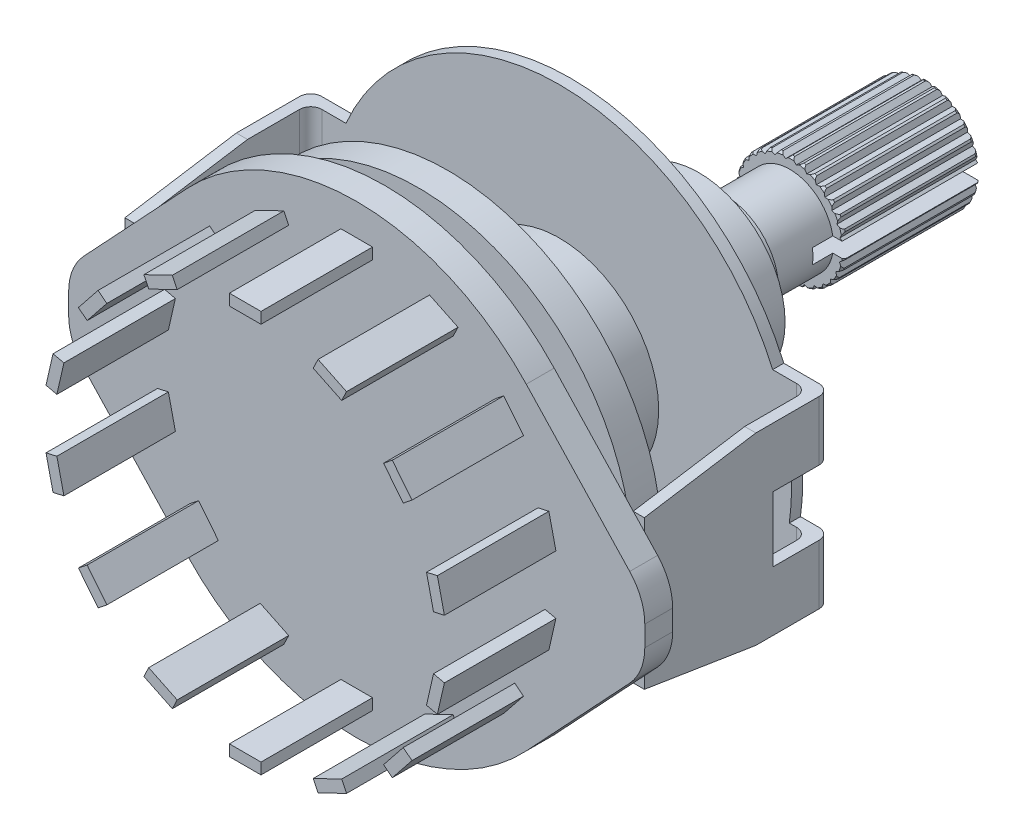
from build123d import *

# Parameters (mm, degrees)
CROQUIS1_R               = 2.95
SALIENTE_EXTRUIR1_DEPTH  = 7.3
CROQUIS2_R               = 2.35
SALIENTE_EXTRUIR2_DEPTH  = 3.5
CROQUIS3_R               = 2.9
SALIENTE_EXTRUIR3_DEPTH  = 1.4
CROQUIS4_R               = 4.65
SALIENTE_EXTRUIR4_DEPTH  = 6
CROQUIS5_R               = 5.35
SALIENTE_EXTRUIR5_DEPTH  = 0.9
SALIENTE_EXTRUIR6_DEPTH  = 0.6
SALIENTE_EXTRUIR7_DEPTH  = 0.6
SALIENTE_EXTRUIR8_DEPTH  = 0.6
REDONDEO1_R              = 0.6
SALIENTE_EXTRUIR9_START  = -0.6
CROQUIS13_W              = 3
CROQUIS13_H              = 0.2
SALIENTE_EXTRUIR9_DEPTH  = 2
CROQUIS14_W              = 0.6
CROQUIS14_H              = 4
SALIENTE_EXTRUIR10_DEPTH = 1.5
SALIENTE_EXTRUIR11_START = 9.4
SALIENTE_EXTRUIR11_DEPTH = 1.5
REDONDEO2_R              = 3
CORTAR_EXTRUIR1_DEPTH    = 7.3
CROQUIS17_W              = 6.48560832
CROQUIS17_H              = 0.8
CORTAR_EXTRUIR2_DEPTH    = 8.4
CROQUIS19_W              = 1.7
CROQUIS19_H              = 0.6
SALIENTE_EXTRUIR12_DEPTH = 6
CROQUIS20_R              = 5.35
SALIENTE_EXTRUIR13_DEPTH = 6
CROQUIS21_R              = 11.5
SALIENTE_EXTRUIR14_DEPTH = 1.6


with BuildPart() as part:
    # Croquis1 → Saliente-Extruir1 (new body)
    with BuildSketch(Plane.XY):
        Circle(CROQUIS1_R)
    extrude(amount=SALIENTE_EXTRUIR1_DEPTH)

    # Croquis2 → Saliente-Extruir2 (add)
    with BuildSketch(Plane.XY.offset(7.3)):
        Circle(CROQUIS2_R)
    extrude(amount=SALIENTE_EXTRUIR2_DEPTH)

    # Croquis3 → Saliente-Extruir3 (add)
    with BuildSketch(Plane.XY.offset(10.8)):
        Circle(CROQUIS3_R)
    extrude(amount=SALIENTE_EXTRUIR3_DEPTH)

    # Croquis4 → Saliente-Extruir4 (add)
    with BuildSketch(Plane.XY.offset(12.2)):
        Circle(CROQUIS4_R)
    extrude(amount=SALIENTE_EXTRUIR4_DEPTH)

    # Croquis5 → Saliente-Extruir5 (add)
    with BuildSketch(Plane.XY.offset(18.2)):
        Circle(CROQUIS5_R)
    extrude(amount=SALIENTE_EXTRUIR5_DEPTH)

    # Croquis6 → Saliente-Extruir6 (add)
    with BuildSketch(Plane.XY.offset(19.1)):
        with BuildLine():
            Line((-5.5, -11.22497216), (5.5, -11.22497216))
            ThreePointArc((5.5, -11.22497216), (0, 12.5), (-5.5, -11.22497216))
        make_face()
    extrude(amount=SALIENTE_EXTRUIR6_DEPTH)

    # Croquis11 → Saliente-Extruir7 (add)
    with BuildSketch(Plane.XY.offset(19.7)):
        with BuildLine():
            Line((-12.376893794, 1.75), (-13.376893794, 1.75))
            Line((-13.376893794, 1.75), (-13.376893794, 4.95))
            Line((-13.376893794, 4.95), (-11.478131381, 4.95))
            ThreePointArc((-11.478131381, 4.95), (-12.034349028, 3.38000643), (-12.376893794, 1.75))
        make_face()
        with BuildLine():
            Line((-11.478131381, -4.95), (-13.376893794, -4.95))
            Line((-13.376893794, -4.95), (-13.376893794, -1.75))
            Line((-13.376893794, -1.75), (-12.376893794, -1.75))
            ThreePointArc((-12.376893794, -1.75), (-12.034349028, -3.38000643), (-11.478131381, -4.95))
        make_face()
    saliente_extruir7 = extrude(amount=-SALIENTE_EXTRUIR7_DEPTH)

    # Croquis12 → Saliente-Extruir8 (add)
    with BuildSketch(Plane.ZY.offset(13.376893794)):
        Polygon((19.1, 4.95), (23.1, 4.95), (29.1, 4), (29.1, -4), (23.1, -4.95), (19.1, -4.95), (19.1, -1.75), (22.18648426, -1.75), (22.18648426, 1.75), (19.1, 1.75), align=None)
    saliente_extruir8 = extrude(amount=SALIENTE_EXTRUIR8_DEPTH)

    # Simetría1: Saliente-Extruir7, Saliente-Extruir8 across plane
    add(saliente_extruir7.mirror(Plane(origin=(0, 0, 0), x_dir=(0, 0, 1), z_dir=(1, 0, 0))))
    add(saliente_extruir8.mirror(Plane(origin=(0, 0, 0), x_dir=(0, 0, 1), z_dir=(1, 0, 0))))

    # Redondeo1
    redondeo1_edges = [part.edges().sort_by_distance(p)[0] for p in [
        (13.976893794, 3.35, 19.1),
        (13.976893794, -3.35, 19.1),
        (-13.376893794, 3.35, 19.7),
        (-13.376893794, -3.35, 19.7),
        (-13.976893794, 3.35, 19.1),
        (-13.976893794, -3.35, 19.1),
        (13.376893794, 3.35, 19.7),
        (13.376893794, -3.35, 19.7),
    ]]
    fillet(redondeo1_edges, radius=REDONDEO1_R)

    # Croquis14 → Saliente-Extruir10 (add)
    with BuildSketch(Plane.XY.offset(29.1)):
        with Locations((13.676893794, 0)):
            Rectangle(CROQUIS14_W, CROQUIS14_H)
    saliente_extruir10 = extrude(amount=SALIENTE_EXTRUIR10_DEPTH)

    # Simetría2: Saliente-Extruir10 across plane
    add(saliente_extruir10.mirror(Plane(origin=(0, 0, 0), x_dir=(0, 0, 1), z_dir=(1, 0, 0))))

    # Croquis15 → Saliente-Extruir11 (add)
    with BuildSketch(Plane.XY.offset(19.7).offset(SALIENTE_EXTRUIR11_START)):
        with BuildLine():
            Line((15.5, 0), (15.5, 1.737141545))
            Line((15.5, 1.737141545), (9.122943906, 8.545284928))
            ThreePointArc((9.122943906, 8.545284928), (0, 12.5), (-9.122943906, 8.545284928))
            Line((-9.122943906, 8.545284928), (-15.5, 1.737141545))
            Line((-15.5, 1.737141545), (-15.5, 0))
            Line((-15.5, 0), (-15.5, -1.737141545))
            Line((-15.5, -1.737141545), (-9.122943906, -8.545284928))
            ThreePointArc((-9.122943906, -8.545284928), (0, -12.5), (9.122943906, -8.545284928))
            Line((9.122943906, -8.545284928), (15.5, -1.737141545))
            Line((15.5, -1.737141545), (15.5, 0))
        make_face()
    extrude(amount=SALIENTE_EXTRUIR11_DEPTH)

    # Redondeo2
    redondeo2_edges = [part.edges().sort_by_distance(p)[0] for p in [
        (-15.5, -1.737141545, 29.85),
        (15.5, -1.737141545, 29.85),
        (15.5, 1.737141545, 29.85),
        (-15.5, 1.737141545, 29.85),
    ]]
    fillet(redondeo2_edges, radius=REDONDEO2_R)

    # Croquis16 → Cortar-Extruir1 (cut)
    with BuildSketch(Plane(origin=(0, 0, 0), x_dir=(-1, 0, 0), z_dir=(0, 0, -1))):
        with BuildLine():
            Line((-0.015316198, 2.949960239), (0.217779302, 2.737792626))
            Line((0.217779302, 2.737792626), (0.483717289, 2.910071749))
            ThreePointArc((0.483717289, 2.910071749), (0.235048226, 2.940621079), (-0.015316198, 2.949960239))
        make_face()
        with BuildLine():
            Line((0.782239396, 2.632686425), (1.078184844, 2.74590922))
            ThreePointArc((1.078184844, 2.74590922), (0.841301359, 2.827492179), (0.598349719, 2.888680947))
            Line((0.598349719, 2.888680947), (0.782239396, 2.632686425))
        make_face()
        with BuildLine():
            Line((1.312511874, 2.412519195), (1.625530547, 2.461737281))
            ThreePointArc((1.625530547, 2.461737281), (1.410785586, 2.590788303), (1.185864882, 2.701152436))
            Line((1.185864882, 2.701152436), (1.312511874, 2.412519195))
        make_face()
        with BuildLine():
            Line((1.785421286, 2.086913299), (2.101832765, 2.069975611))
            ThreePointArc((2.101832765, 2.069975611), (1.918611712, 2.240854546), (1.721552059, 2.395570601))
            Line((1.721552059, 2.395570601), (1.785421286, 2.086913299))
        make_face()
        with BuildLine():
            Line((2.18029922, 1.670099278), (2.486274805, 1.587746073))
            ThreePointArc((2.486274805, 1.587746073), (2.342585301, 1.792984693), (2.181999151, 1.985290837))
            Line((2.181999151, 1.985290837), (2.18029922, 1.670099278))
        make_face()
        with BuildLine():
            Line((2.479887615, 1.180293905), (2.762054706, 1.036124414))
            ThreePointArc((2.762054706, 1.036124414), (2.664176671, 1.266752805), (2.547082409, 1.488244336))
            Line((2.547082409, 1.488244336), (2.479887615, 1.180293905))
        make_face()
        with BuildLine():
            Line((2.671093022, 0.638904024), (2.917119563, 0.439219145))
            ThreePointArc((2.917119563, 0.439219145), (2.869330736, 0.68515774), (2.800845943, 0.926154416))
            Line((2.800845943, 0.926154416), (2.671093022, 0.638904024))
        make_face()
        with BuildLine():
            Line((2.745558847, 0.069590972), (2.944692296, -0.176882107))
            ThreePointArc((2.944692296, -0.176882107), (2.949081279, 0.073617995), (2.93219907, 0.323587104))
            Line((2.93219907, 0.323587104), (2.745558847, 0.069590972))
        make_face()
        with BuildLine():
            Line((2.700030576, -0.50276354), (2.843567847, -0.785252763))
            ThreePointArc((2.843567847, -0.785252763), (2.899942819, -0.54113921), (2.935401027, -0.293122517))
            Line((2.935401027, -0.293122517), (2.700030576, -0.50276354))
        make_face()
        with BuildLine():
            Line((2.536498012, -1.053144873), (2.618165837, -1.359304105))
            ThreePointArc((2.618165837, -1.359304105), (2.724062943, -1.132246035), (2.810311874, -0.897021277))
            Line((2.810311874, -0.897021277), (2.536498012, -1.053144873))
        make_face()
        with BuildLine():
            Line((2.262108313, -1.557498721), (2.278337417, -1.873947335))
            ThreePointArc((2.278337417, -1.873947335), (2.429128444, -1.673868274), (2.562398606, -1.461715904))
            Line((2.562398606, -1.461715904), (2.262108313, -1.557498721))
        make_face()
        with BuildLine():
            Line((1.888853627, -1.993782401), (1.838934719, -2.306690074))
            ThreePointArc((1.838934719, -2.306690074), (2.028029377, -2.142334439), (2.202496224, -1.962526531))
            Line((2.202496224, -1.962526531), (1.888853627, -1.993782401))
        make_face()
        with BuildLine():
            Line((1.433046973, -2.342928223), (1.31916175, -2.638619389))
            ThreePointArc((1.31916175, -2.638619389), (1.538295694, -2.517170308), (1.746334188, -2.377565331))
            Line((1.746334188, -2.377565331), (1.433046973, -2.342928223))
        make_face()
        with BuildLine():
            Line((0.91460929, -2.58967684), (0.741735082, -2.855228374))
            ThreePointArc((0.741735082, -2.855228374), (0.981331107, -2.781993756), (1.213848968, -2.688693118))
            Line((1.213848968, -2.688693118), (0.91460929, -2.58967684))
        make_face()
        with BuildLine():
            Line((0.356198792, -2.723244151), (0.131891032, -2.947050179))
            ThreePointArc((0.131891032, -2.947050179), (0.381477642, -2.925230727), (0.628312723, -2.882312114))
            Line((0.628312723, -2.882312114), (0.356198792, -2.723244151))
        make_face()
        with BuildLine():
            Line((-0.217779302, -2.737792626), (-0.483717289, -2.910071749))
            ThreePointArc((-0.483717289, -2.910071749), (-0.235048226, -2.940621079), (0.015316198, -2.949960239))
            Line((0.015316198, -2.949960239), (-0.217779302, -2.737792626))
        make_face()
        with BuildLine():
            Line((-0.782239396, -2.632686425), (-1.078184844, -2.74590922))
            ThreePointArc((-1.078184844, -2.74590922), (-0.841301359, -2.827492179), (-0.598349719, -2.888680947))
            Line((-0.598349719, -2.888680947), (-0.782239396, -2.632686425))
        make_face()
        with BuildLine():
            Line((-1.312511874, -2.412519195), (-1.625530547, -2.461737281))
            ThreePointArc((-1.625530547, -2.461737281), (-1.410785586, -2.590788303), (-1.185864882, -2.701152436))
            Line((-1.185864882, -2.701152436), (-1.312511874, -2.412519195))
        make_face()
        with BuildLine():
            Line((-1.785421286, -2.086913299), (-2.101832765, -2.069975611))
            ThreePointArc((-2.101832765, -2.069975611), (-1.918611712, -2.240854546), (-1.721552059, -2.395570601))
            Line((-1.721552059, -2.395570601), (-1.785421286, -2.086913299))
        make_face()
        with BuildLine():
            Line((-2.18029922, -1.670099278), (-2.486274805, -1.587746073))
            ThreePointArc((-2.486274805, -1.587746073), (-2.342585301, -1.792984693), (-2.181999151, -1.985290837))
            Line((-2.181999151, -1.985290837), (-2.18029922, -1.670099278))
        make_face()
        with BuildLine():
            Line((-2.479887615, -1.180293905), (-2.762054706, -1.036124414))
            ThreePointArc((-2.762054706, -1.036124414), (-2.664176671, -1.266752805), (-2.547082409, -1.488244336))
            Line((-2.547082409, -1.488244336), (-2.479887615, -1.180293905))
        make_face()
        with BuildLine():
            Line((-2.671093022, -0.638904024), (-2.917119563, -0.439219145))
            ThreePointArc((-2.917119563, -0.439219145), (-2.869330736, -0.68515774), (-2.800845943, -0.926154416))
            Line((-2.800845943, -0.926154416), (-2.671093022, -0.638904024))
        make_face()
        with BuildLine():
            Line((-2.745558847, -0.069590972), (-2.944692296, 0.176882107))
            ThreePointArc((-2.944692296, 0.176882107), (-2.949081279, -0.073617995), (-2.93219907, -0.323587104))
            Line((-2.93219907, -0.323587104), (-2.745558847, -0.069590972))
        make_face()
        with BuildLine():
            Line((-2.700030576, 0.50276354), (-2.843567847, 0.785252763))
            ThreePointArc((-2.843567847, 0.785252763), (-2.899942819, 0.54113921), (-2.935401027, 0.293122517))
            Line((-2.935401027, 0.293122517), (-2.700030576, 0.50276354))
        make_face()
        with BuildLine():
            Line((-2.536498012, 1.053144873), (-2.618165837, 1.359304105))
            ThreePointArc((-2.618165837, 1.359304105), (-2.724062943, 1.132246035), (-2.810311874, 0.897021277))
            Line((-2.810311874, 0.897021277), (-2.536498012, 1.053144873))
        make_face()
        with BuildLine():
            Line((-2.262108313, 1.557498721), (-2.278337417, 1.873947335))
            ThreePointArc((-2.278337417, 1.873947335), (-2.429128444, 1.673868274), (-2.562398606, 1.461715904))
            Line((-2.562398606, 1.461715904), (-2.262108313, 1.557498721))
        make_face()
        with BuildLine():
            Line((-1.888853627, 1.993782401), (-1.838934719, 2.306690074))
            ThreePointArc((-1.838934719, 2.306690074), (-2.028029377, 2.142334439), (-2.202496224, 1.962526531))
            Line((-2.202496224, 1.962526531), (-1.888853627, 1.993782401))
        make_face()
        with BuildLine():
            Line((-1.433046973, 2.342928223), (-1.31916175, 2.638619389))
            ThreePointArc((-1.31916175, 2.638619389), (-1.538295694, 2.517170308), (-1.746334188, 2.377565331))
            Line((-1.746334188, 2.377565331), (-1.433046973, 2.342928223))
        make_face()
        with BuildLine():
            Line((-0.91460929, 2.58967684), (-0.741735082, 2.855228374))
            ThreePointArc((-0.741735082, 2.855228374), (-0.981331107, 2.781993756), (-1.213848968, 2.688693118))
            Line((-1.213848968, 2.688693118), (-0.91460929, 2.58967684))
        make_face()
        with BuildLine():
            Line((-0.356198792, 2.723244151), (-0.131891032, 2.947050179))
            ThreePointArc((-0.131891032, 2.947050179), (-0.381477642, 2.925230727), (-0.628312723, 2.882312114))
            Line((-0.628312723, 2.882312114), (-0.356198792, 2.723244151))
        make_face()
    extrude(amount=-CORTAR_EXTRUIR1_DEPTH, mode=Mode.SUBTRACT)

    # Croquis17 → Cortar-Extruir2 (cut)
    with BuildSketch(Plane(origin=(0, 0, 0), x_dir=(-1, 0, 0), z_dir=(0, 0, -1))):
        Rectangle(CROQUIS17_W, CROQUIS17_H)
    extrude(amount=-CORTAR_EXTRUIR2_DEPTH, mode=Mode.SUBTRACT)

    # Croquis18 → Cortar-Revolución1 (revolve, cut)
    with BuildSketch(Plane(origin=(0, 0, 0), x_dir=(1, 0, 0), z_dir=(0, 1, 0))):
        with BuildLine():
            Line((2.782744284, 0.042906343), (2.977685316, 0.042906343))
            Line((2.977685316, 0.042906343), (2.977685316, -0.149209457))
            Line((2.977685316, -0.149209457), (2.952258225, -0.149209457))
            add(Edge.make_bspline(
                [(2.782744284, 0.042906343), (2.912548704, -0.013421123), (2.952258225, -0.149209457)],
                knots=[0, 0, 0, 1, 1, 1], degree=2))
        make_face()
        with BuildLine():
            Line((2.977685316, -7.342906343), (2.977685316, -7.150790543))
            Line((2.977685316, -7.150790543), (2.952258225, -7.150790543))
            add(Edge.make_bspline(
                [(2.782744284, -7.342906343), (2.912548704, -7.286578877), (2.952258225, -7.150790543)],
                knots=[0, 0, 0, 1, 1, 1], degree=2))
            Line((2.782744284, -7.342906343), (2.977685316, -7.342906343))
        make_face()
    revolve(axis=Axis((0, 0, 0), (0, 0, -1)), mode=Mode.SUBTRACT)

    # Croquis19 → Saliente-Extruir12 (add)
    with BuildSketch(Plane.XY.offset(30.6)):
        Polygon((3.920120845, 10.099264952), (3.659790601, 9.558683631), (5.191437677, 8.821081274), (5.45176792, 9.361662595), align=None)
        with Locations((0, 10.5)):
            Rectangle(CROQUIS19_W, CROQUIS19_H)
        Polygon((7.913813679, 7.39824662), (7.44471479, 7.024152739), (8.504647453, 5.695039219), (8.973746342, 6.0691331), align=None)
        Polygon((10.340078658, 3.231914812), (9.75512191, 3.098402252), (10.133407498, 1.441024801), (10.718364245, 1.574537361), align=None)
        Polygon((10.718364245, -1.574537361), (10.133407498, -1.441024801), (9.75512191, -3.098402252), (10.340078658, -3.231914812), align=None)
        Polygon((8.973746342, -6.0691331), (8.504647453, -5.695039219), (7.44471479, -7.024152739), (7.913813679, -7.39824662), align=None)
        Polygon((5.45176792, -9.361662595), (5.191437677, -8.821081274), (3.659790601, -9.558683631), (3.920120845, -10.099264952), align=None)
        with Locations((0, -10.5)):
            Rectangle(CROQUIS19_W, CROQUIS19_H)
        Polygon((-3.920120845, -10.099264952), (-3.659790601, -9.558683631), (-5.191437677, -8.821081274), (-5.45176792, -9.361662595), align=None)
        Polygon((-7.913813679, -7.39824662), (-7.44471479, -7.024152739), (-8.504647453, -5.695039219), (-8.973746342, -6.0691331), align=None)
        Polygon((-10.340078658, -3.231914812), (-9.75512191, -3.098402252), (-10.133407498, -1.441024801), (-10.718364245, -1.574537361), align=None)
        Polygon((-10.718364245, 1.574537361), (-10.133407498, 1.441024801), (-9.75512191, 3.098402252), (-10.340078658, 3.231914812), align=None)
        Polygon((-8.973746342, 6.0691331), (-8.504647453, 5.695039219), (-7.44471479, 7.024152739), (-7.913813679, 7.39824662), align=None)
        Polygon((-5.45176792, 9.361662595), (-5.191437677, 8.821081274), (-3.659790601, 9.558683631), (-3.920120845, 10.099264952), align=None)
    extrude(amount=SALIENTE_EXTRUIR12_DEPTH)

    # Croquis20 → Saliente-Extruir13 (add)
    with BuildSketch(Plane.XY.offset(19.7)):
        Circle(CROQUIS20_R)
    extrude(amount=SALIENTE_EXTRUIR13_DEPTH)

    # Croquis21 → Saliente-Extruir14 (add)
    with BuildSketch(Plane.XY.offset(25.7)):
        Circle(CROQUIS21_R)
    extrude(amount=SALIENTE_EXTRUIR14_DEPTH)


with BuildPart() as body_2:
    # Croquis13 → Saliente-Extruir9 (new body)
    with BuildSketch(Plane(origin=(0, 0, 19.1), x_dir=(-1, 0, 0), z_dir=(0, 0, -1)).offset(SALIENTE_EXTRUIR9_START)):
        with Locations((0, -11.32497216)):
            Rectangle(CROQUIS13_W, CROQUIS13_H)
    extrude(amount=SALIENTE_EXTRUIR9_DEPTH)


solid = Compound([part.part, body_2.part])
